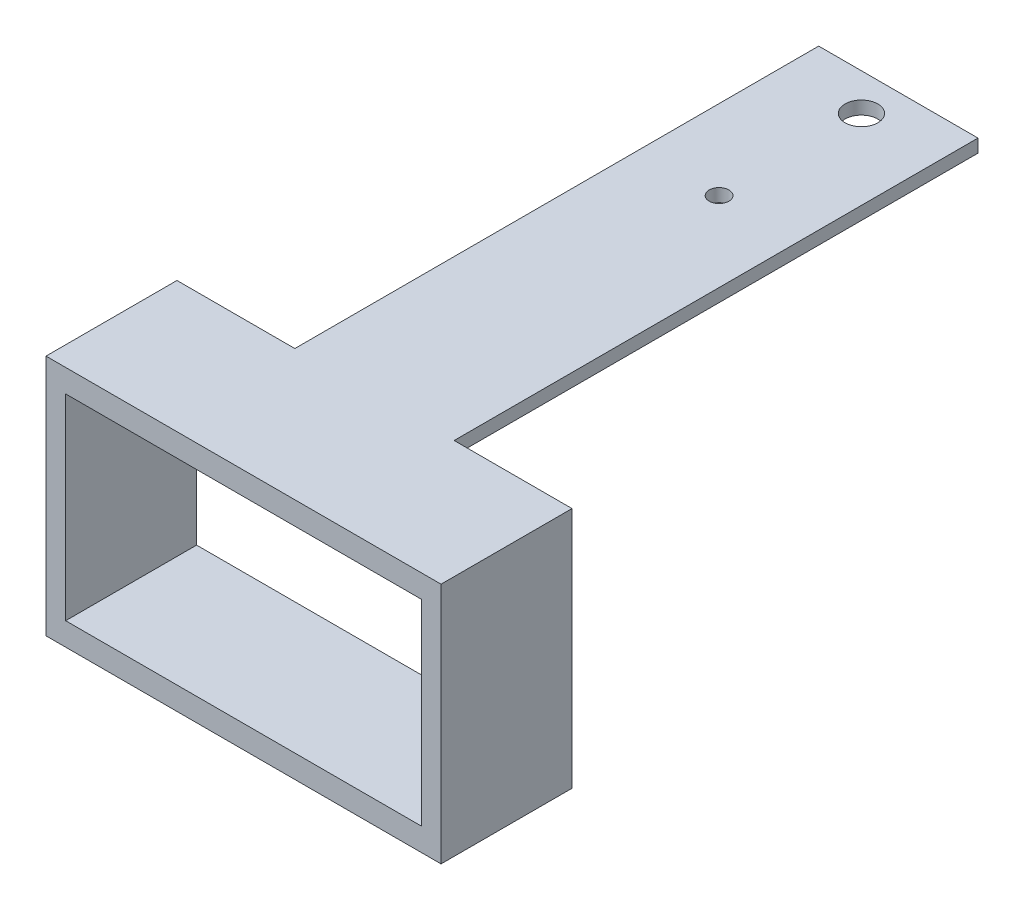
from build123d import *

# Parameters (mm, degrees)
BOSS_EXTRUDE1_DEPTH = 2
SKETCH3_W           = 60.33
SKETCH3_H           = 20
BOSS_EXTRUDE2_DEPTH = 30
SKETCH4_W           = 54.33
SKETCH4_H           = 27
CUT_EXTRUDE1_DEPTH  = 20
SKETCH5_R           = 1.5
CUT_EXTRUDE2_DEPTH  = 2
SKETCH6_W           = 60.33
SKETCH6_H           = 20
BOSS_EXTRUDE3_DEPTH = 5
SKETCH8_W           = 54.33
SKETCH8_H           = 20
CUT_EXTRUDE3_DEPTH  = 3
SKETCH9_W           = 24.33
SKETCH9_H           = 20
BOSS_EXTRUDE4_DEPTH = 2
SKETCH10_R          = 2.5
CUT_EXTRUDE4_DEPTH  = 2


with BuildPart() as part:
    # Sketch2 → Boss-Extrude1 (new body)
    with BuildSketch(Plane(origin=(0, 0, 0), x_dir=(1, 0, 0), z_dir=(0, 1, 0))):
        Polygon((-7.941176471, 23.529411765), (16.388823529, 23.529411765), (16.388823529, -36.470588235), (34.388823529, -36.470588235), (34.388823529, -56.470588235), (-25.941176471, -56.470588235), (-25.941176471, -36.470588235), (-7.941176471, -36.470588235), align=None)
    extrude(amount=BOSS_EXTRUDE1_DEPTH)

    # Sketch3 → Boss-Extrude2 (add)
    with BuildSketch(Plane(origin=(0, 0, 0), x_dir=(-1, 0, 0), z_dir=(0, -1, 0))):
        with Locations((-4.223823529, -46.470588235)):
            Rectangle(SKETCH3_W, SKETCH3_H)
    extrude(amount=BOSS_EXTRUDE2_DEPTH)

    # Sketch4 → Cut-Extrude1 (cut)
    with BuildSketch(Plane(origin=(0, 0, 36.470588235), x_dir=(-1, 0, 0), z_dir=(0, 0, -1))):
        with Locations((-4.223823529, -15)):
            Rectangle(SKETCH4_W, SKETCH4_H)
    extrude(amount=-CUT_EXTRUDE1_DEPTH, mode=Mode.SUBTRACT)

    # Sketch5 → Cut-Extrude2 (cut)
    with BuildSketch(Plane(origin=(0, 0, 0), x_dir=(-1, 0, 0), z_dir=(0, -1, 0))):
        with Locations((-4.223823529, 16.1506031)):
            Circle(SKETCH5_R)
    extrude(amount=-CUT_EXTRUDE2_DEPTH, mode=Mode.SUBTRACT)

    # Sketch6 → Boss-Extrude3 (add)
    with BuildSketch(Plane.XZ.offset(30)):
        with Locations((4.223823529, 46.470588235)):
            Rectangle(SKETCH6_W, SKETCH6_H)
    extrude(amount=BOSS_EXTRUDE3_DEPTH)

    # Sketch8 → Cut-Extrude3 (cut)
    with BuildSketch(Plane(origin=(0, -28.5, 0), x_dir=(1, 0, 0), z_dir=(0, 1, 0))):
        with Locations((4.223823529, -46.470588235)):
            Rectangle(SKETCH8_W, SKETCH8_H)
    extrude(amount=-CUT_EXTRUDE3_DEPTH, mode=Mode.SUBTRACT)

    # Sketch9 → Boss-Extrude4 (add)
    with BuildSketch(Plane(origin=(0, 2, 0), x_dir=(1, 0, 0), z_dir=(0, 1, 0))):
        with Locations((4.223823529, 33.529411765)):
            Rectangle(SKETCH9_W, SKETCH9_H)
    extrude(amount=-BOSS_EXTRUDE4_DEPTH)

    # Sketch10 → Cut-Extrude4 (cut)
    with BuildSketch(Plane(origin=(0, 0, 0), x_dir=(-1, 0, 0), z_dir=(0, -1, 0))):
        with Locations((-4.223823529, 37.893427201)):
            Circle(SKETCH10_R)
    extrude(amount=-CUT_EXTRUDE4_DEPTH, mode=Mode.SUBTRACT)


solid = part.part
